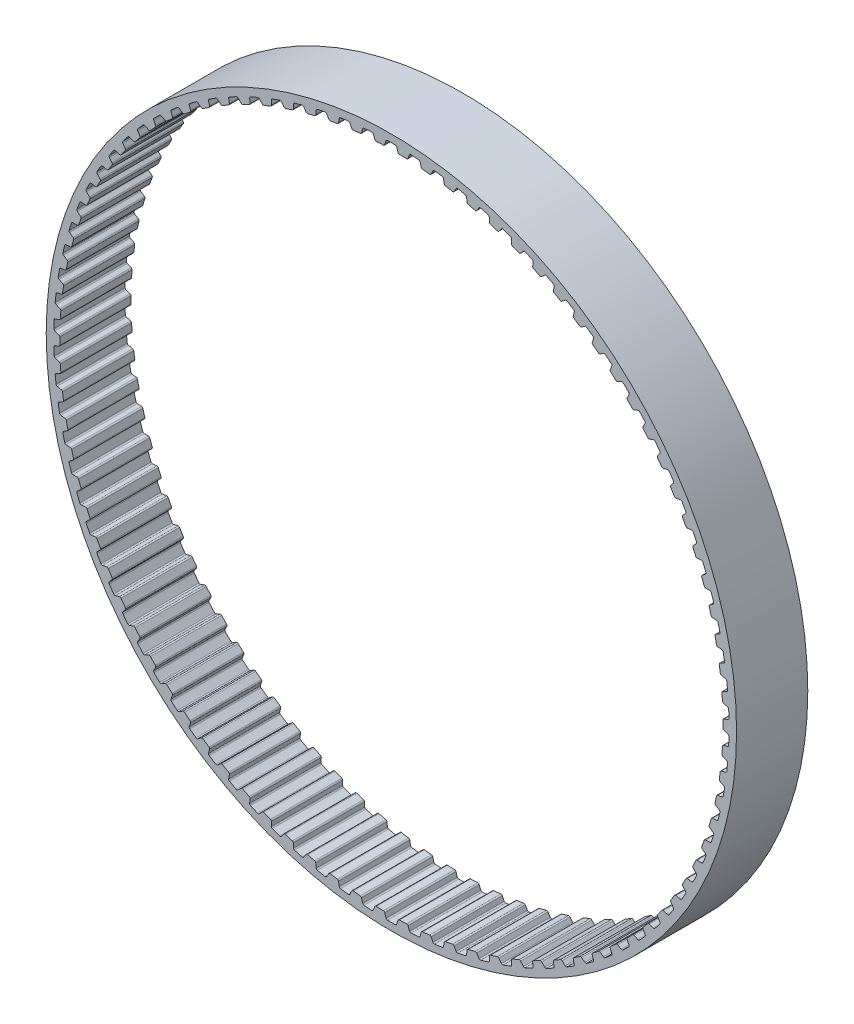
from build123d import *

# Parameters (mm, degrees)
SKETCH4_R           = 29.077632664
SKETCH4_R_2         = 27.934632664
BOSS_EXTRUDE1_DEPTH = 3
CUT_EXTRUDE1_DEPTH  = 3
CIRPATTERN1_COUNT   = 90


with BuildPart() as part:
    # Sketch4 → Boss-Extrude1 (new body, symmetric)
    with BuildSketch(Plane.XY):
        Circle(SKETCH4_R)
        Circle(SKETCH4_R_2, mode=Mode.SUBTRACT)
    extrude(amount=BOSS_EXTRUDE1_DEPTH, both=True)

    # Sketch3 → Cut-Extrude1 (cut, symmetric)
    with BuildSketch(Plane.XY):
        with BuildLine():
            Line((-0.676850578, 27.926431483), (0.676850578, 27.926431483))
            ThreePointArc((0.676850578, 27.926431483), (0.604039676, 27.951561009), (0.559143585, 28.014149039))
            Line((0.559143585, 28.014149039), (0.449052382, 28.352974922))
            ThreePointArc((0.449052382, 28.352974922), (0.403511259, 28.41604048), (0.329740538, 28.440721229))
            ThreePointArc((0.329740538, 28.440721229), (0, 28.442632664), (-0.329740538, 28.440721229))
            ThreePointArc((-0.329740538, 28.440721229), (-0.403511259, 28.41604048), (-0.449052382, 28.352974922))
            Line((-0.449052382, 28.352974922), (-0.559143585, 28.014149039))
            ThreePointArc((-0.559143585, 28.014149039), (-0.604039676, 27.951561009), (-0.676850578, 27.926431483))
        make_face()
    cut_extrude1 = extrude(amount=CUT_EXTRUDE1_DEPTH, both=True, mode=Mode.SUBTRACT)

    # CirPattern1: Cut-Extrude1 ×90 about axis
    cirpattern1_axis = Axis((0, 0, 0), (0, 0, 1))
    for i in range(1, CIRPATTERN1_COUNT):
        add(cut_extrude1.rotate(cirpattern1_axis, i * 360 / CIRPATTERN1_COUNT), mode=Mode.SUBTRACT)


solid = part.part
